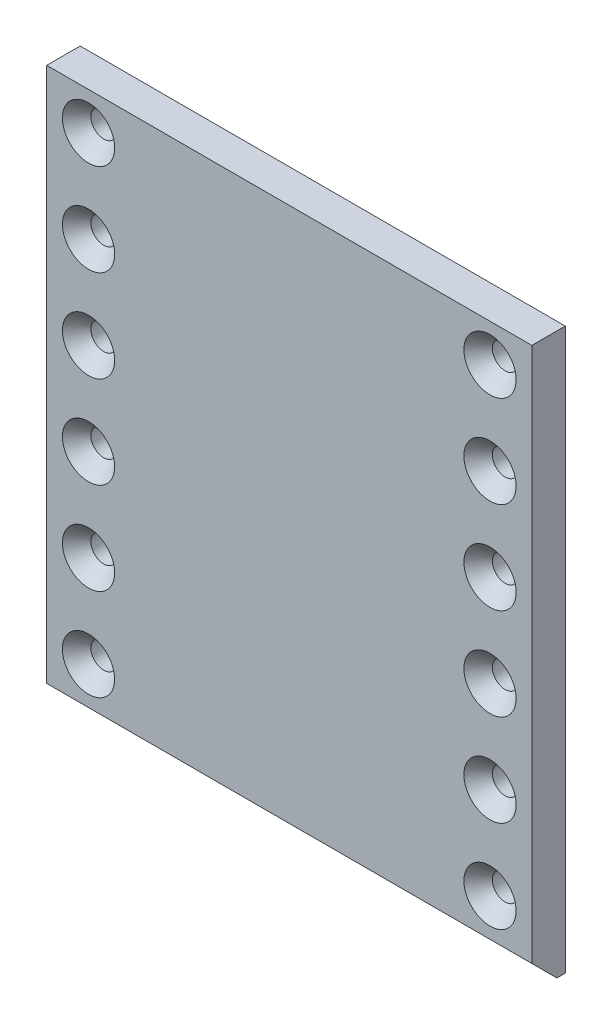
from build123d import *

# Parameters (mm, degrees)
SKETCH1_W                                           = 184.15
SKETCH1_H                                           = 212.725
BOSS_EXTRUDE1_DEPTH                                 = 6.35
CSK_FOR_3_8_FLAT_HEAD_SOCKET_CAP_SCREW1_D           = 9.8044
CSK_FOR_3_8_FLAT_HEAD_SOCKET_CAP_SCREW1_CSINK_D     = 19.8374
CSK_FOR_3_8_FLAT_HEAD_SOCKET_CAP_SCREW1_CSINK_ANGLE = 82
CHAMFER1_SIZE                                       = 9.525


with BuildPart() as part:
    # Sketch1 → Boss-Extrude1 (new body, symmetric)
    with BuildSketch(Plane.XY):
        Rectangle(SKETCH1_W, SKETCH1_H)
    extrude(amount=BOSS_EXTRUDE1_DEPTH, both=True)

    # CSK for 3/8 Flat Head Socket Cap Screw1 (through all)
    with Locations(Plane.XY.offset(6.35)):
        with Locations((-76.2, 92.075), (-76.2, 57.15), (-76.2, 22.225), (-76.2, -12.7), (-76.2, -47.625), (-76.2, -82.55), (76.2, -82.55), (76.2, -47.625), (76.2, -12.7), (76.2, 22.225), (76.2, 57.15), (76.2, 92.075)):
            CounterSinkHole(CSK_FOR_3_8_FLAT_HEAD_SOCKET_CAP_SCREW1_D / 2, CSK_FOR_3_8_FLAT_HEAD_SOCKET_CAP_SCREW1_CSINK_D / 2, counter_sink_angle=CSK_FOR_3_8_FLAT_HEAD_SOCKET_CAP_SCREW1_CSINK_ANGLE)

    # Chamfer1
    chamfer1_edges = [part.edges().sort_by_distance(p)[0] for p in [
        (0, -106.3625, 6.35),
    ]]
    chamfer(chamfer1_edges, length=CHAMFER1_SIZE)


solid = part.part
